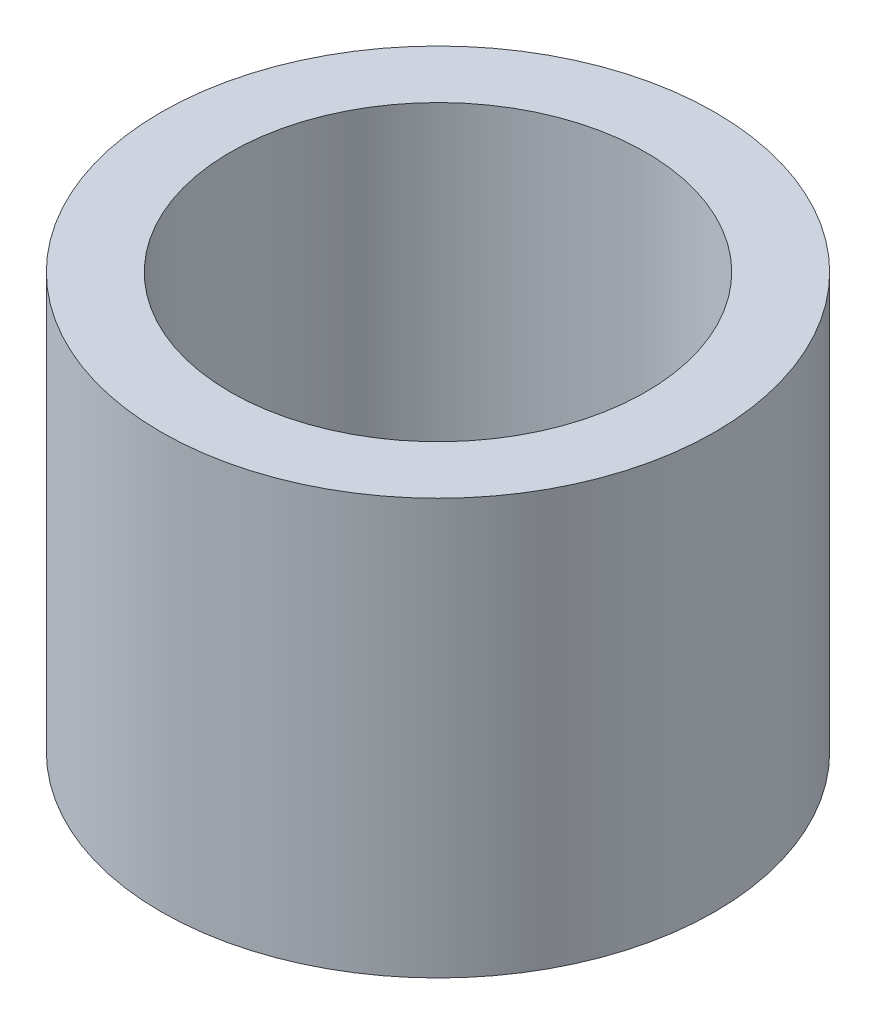
from build123d import *

# Parameters (mm, degrees)
SKETCH1_R           = 25.4
SKETCH1_R_2         = 19.05
BOSS_EXTRUDE1_DEPTH = 38.1


with BuildPart() as part:
    # Sketch1 → Boss-Extrude1 (new body)
    with BuildSketch(Plane(origin=(0, 0, 0), x_dir=(1, 0, 0), z_dir=(0, 1, 0))):
        Circle(SKETCH1_R)
        Circle(SKETCH1_R_2, mode=Mode.SUBTRACT)
    extrude(amount=BOSS_EXTRUDE1_DEPTH)


solid = part.part
